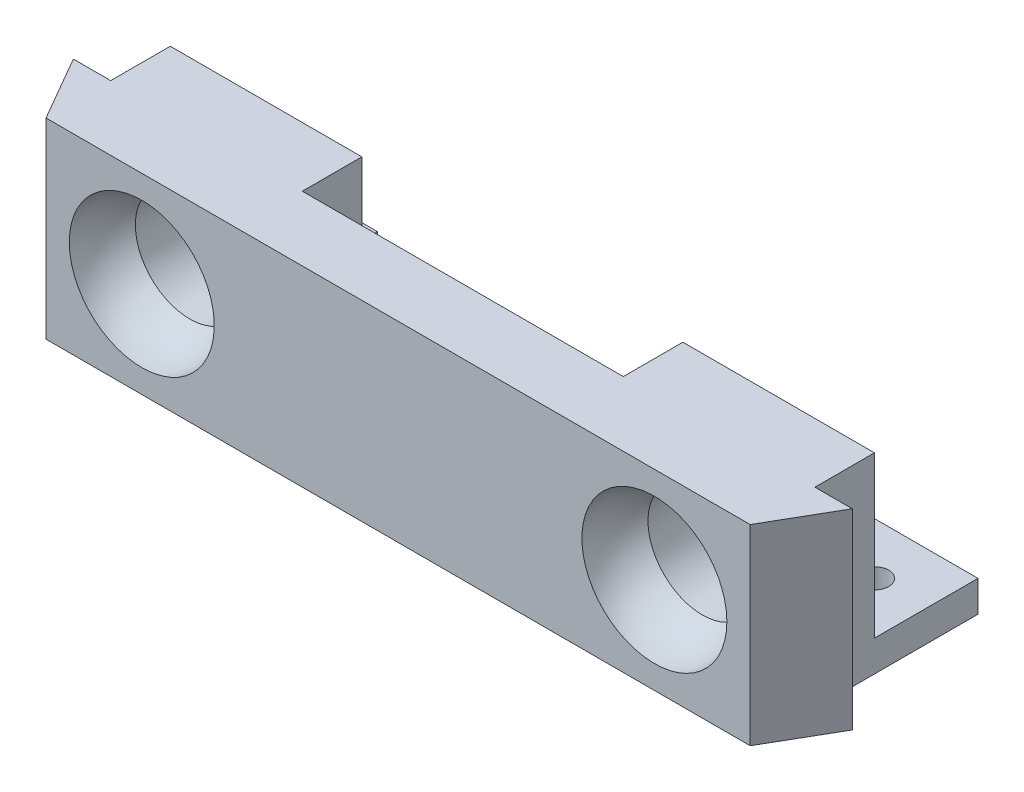
from build123d import *

# Parameters (mm, degrees)
BOSS_EXTRUDE1_DEPTH = 18.5
SKETCH3_W           = 10
SKETCH3_H           = 10
BOSS_EXTRUDE2_DEPTH = 3
SKETCH5_R           = 1.375
CUT_EXTRUDE1_DEPTH  = 3


with BuildPart() as part:
    # Sketch1 → Boss-Extrude1 (new body)
    with BuildSketch(Plane(origin=(0, 0, 0), x_dir=(1, 0, 0), z_dir=(0, 1, 0))):
        Polygon((-34, 0), (-37.608439182, 6.25), (-34, 6.25), (-34, 12), (-15.5, 12), (-15.5, 6.25), (15.5, 6.25), (15.5, 12), (34, 12), (34, 6.25), (37.608439182, 6.25), (34, 0), align=None)
    extrude(amount=BOSS_EXTRUDE1_DEPTH)

    # Sketch2 → Cut-Revolve1 (revolve, cut)
    with BuildSketch(Plane(origin=(0, 9.25, 0), x_dir=(1, 0, 0), z_dir=(0, 1, 0))):
        with BuildLine():
            Line((-24.75, 12), (-24.75, 0))
            Line((-24.75, 0), (-31.75, 0))
            ThreePointArc((-31.75, 0), (-31.297900427, 2.474873734), (-30, 4.630064794))
            Line((-30, 4.630064794), (-30, 12))
            Line((-30, 12), (-24.75, 12))
        make_face()
    cut_revolve1 = revolve(axis=Axis((-24.75, 9.25, -35.715820775), (0, 0, 1)), mode=Mode.SUBTRACT)

    # Mirror1: Cut-Revolve1 across plane
    add(cut_revolve1.mirror(Plane(origin=(0, 0, 0), x_dir=(0, 0, 1), z_dir=(1, 0, 0))), mode=Mode.SUBTRACT)

    # Sketch3 → Boss-Extrude2 (add)
    with BuildSketch(Plane(origin=(0, 0, 0), x_dir=(1, 0, 0), z_dir=(0, 1, 0))):
        with Locations((-29, 17)):
            Rectangle(SKETCH3_W, SKETCH3_H)
        with Locations((29, 17)):
            Rectangle(SKETCH3_W, SKETCH3_H)
    extrude(amount=BOSS_EXTRUDE2_DEPTH)

    # Sketch5 → Cut-Extrude1 (cut)
    with BuildSketch(Plane(origin=(0, 3, 0), x_dir=(1, 0, 0), z_dir=(0, 1, 0))):
        with Locations((-29, 17)):
            Circle(SKETCH5_R)
    cut_extrude1 = extrude(amount=-CUT_EXTRUDE1_DEPTH, mode=Mode.SUBTRACT)

    # Mirror2: Cut-Extrude1 across plane
    add(cut_extrude1.mirror(Plane(origin=(0, 0, 0), x_dir=(0, 0, 1), z_dir=(1, 0, 0))), mode=Mode.SUBTRACT)


solid = part.part
